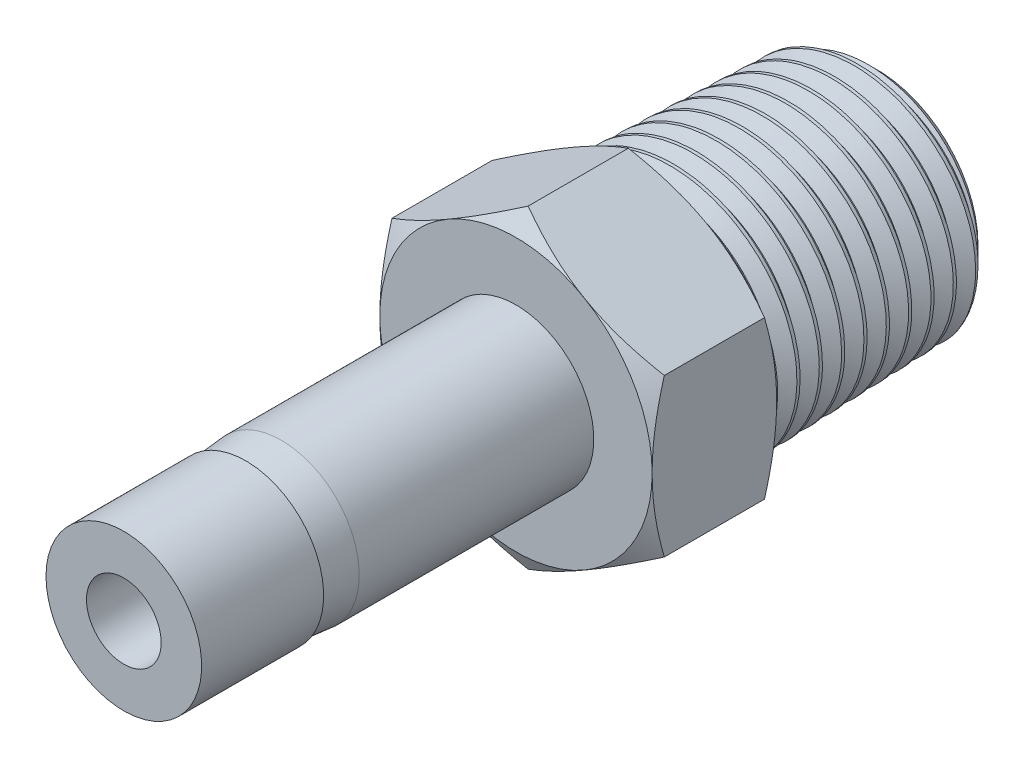
from build123d import *

# Parameters (mm, degrees)
BOSS_EXTRUDE1_DEPTH    = 5.08
SKETCH4_W              = 21.082
SKETCH4_H              = 1.524
CUT_SWEEP1_PITCH       = 0.941196605
CUT_SWEEP1_HEIGHT      = 10.907700741
CUT_SWEEP1_RADIUS      = 4.833177772
CUT_SWEEP1_START_ANGLE = 90


with BuildPart() as part:
    # Sketch2 → Revolve1 (revolve)
    with BuildSketch(Plane(origin=(0, 0, 0), x_dir=(0, 0, -1), z_dir=(1, 0, 0)), mode=Mode.PRIVATE) as revolve1_sk:
        Polygon((4.9784, 3.175), (4.9784, 3.048), (6.430016642, 3.175), (16.002, 3.175), (16.002, 0), (0, 0), (0, 3.175), align=None)
    revolve(revolve1_sk.sketch.rotate(Axis((0, 0, -16.002), (0, 0, 1)), 90), axis=Axis((0, 0, -16.002), (0, 0, 1)))

    # Sketch3 → Boss-Extrude1 (add)
    with BuildSketch(Plane(origin=(0, 0, -16.002), x_dir=(-1, 0, 0), z_dir=(0, 0, -1))):
        Polygon((0, 6.415804866), (-5.55625, 3.207902433), (-5.55625, -3.207902433), (0, -6.415804866), (5.55625, -3.207902433), (5.55625, 3.207902433), align=None)
    extrude(amount=BOSS_EXTRUDE1_DEPTH)

    # Sketch4 → Cut-Revolve1 (revolve, cut)
    with BuildSketch(Plane(origin=(0, 0, 0), x_dir=(0, 0, -1), z_dir=(1, 0, 0)), mode=Mode.PRIVATE) as cut_revolve1_sk:
        Polygon((16.002, 6.415804866), (16.002, 5.55625), (16.498264233, 6.415804866), (20.585735767, 6.415804866), (21.082, 5.55625), (21.082, 6.415804866), (21.082, 7.275359733), (16.002, 7.275359733), align=None)
        with Locations((10.541, 0.762)):
            Rectangle(SKETCH4_W, SKETCH4_H)
    revolve(cut_revolve1_sk.sketch.rotate(Axis((0, 0, 0), (0, 0, -1)), 90), axis=Axis((0, 0, 0), (0, 0, -1)), mode=Mode.SUBTRACT)


with BuildPart() as body_2:
    # Sketch5 → Revolve2 (revolve)
    with BuildSketch(Plane(origin=(0, 0, 0), x_dir=(0, 0, -1), z_dir=(1, 0, 0)), mode=Mode.PRIVATE) as revolve2_sk:
        Polygon((20.76704, 0), (30.734, 0), (30.734, 4.833177772), (20.76704, 5.1435), align=None)
    revolve(revolve2_sk.sketch.rotate(Axis((0, 0, -20.76704), (0, 0, -1)), 90), axis=Axis((0, 0, -20.76704), (0, 0, -1)))

    # Cut-Sweep1: sweep along a helix
    with BuildLine() as cut_sweep1_path:
        # a taper helix: rise per turn along the axis 0.940740741, along the cone's slant (build123d's pitch) 0.941196605
        add(Helix(CUT_SWEEP1_PITCH, CUT_SWEEP1_HEIGHT, CUT_SWEEP1_RADIUS, center=(0, 0, -30.734), direction=(0, 0, 1), cone_angle=1.783333333, mode=Mode.PRIVATE).rotate(Axis((0, 0, -30.734), (0, 0, 1)), CUT_SWEEP1_START_ANGLE))
    # Sketch7 → Cut-Sweep1 (sweep, cut)
    with BuildSketch(Plane(origin=(0, 0, 0), x_dir=(0, 0, -1), z_dir=(1, 0, 0))):
        Polygon((30.675203704, 4.935015945), (31.586546296, 4.884096858), (31.20437037, 4.222148737), (31.086777778, 4.222148737), align=None)
    sweep(path=cut_sweep1_path.line, is_frenet=True, mode=Mode.SUBTRACT)


with BuildPart() as part_1:
    add(part.part)

    # Combine1: union body 2
    add(body_2.part)

    # Sketch8 → Cut-Revolve2 (revolve, cut)
    with BuildSketch(Plane(origin=(0, 0, 0), x_dir=(0, 0, -1), z_dir=(1, 0, 0)), mode=Mode.PRIVATE) as cut_revolve2_sk:
        Polygon((30.734, 4.120310565), (29.91929462, 4.935015945), (30.734, 4.935015945), align=None)
        Polygon((30.734, 3.4163), (20.76704, 3.4163), (18.714319867, 0), (30.734, 0), align=None)
    revolve(cut_revolve2_sk.sketch.rotate(Axis((0, 0, 0), (0, 0, -1)), 90), axis=Axis((0, 0, 0), (0, 0, -1)), mode=Mode.SUBTRACT)


solid = part_1.part
